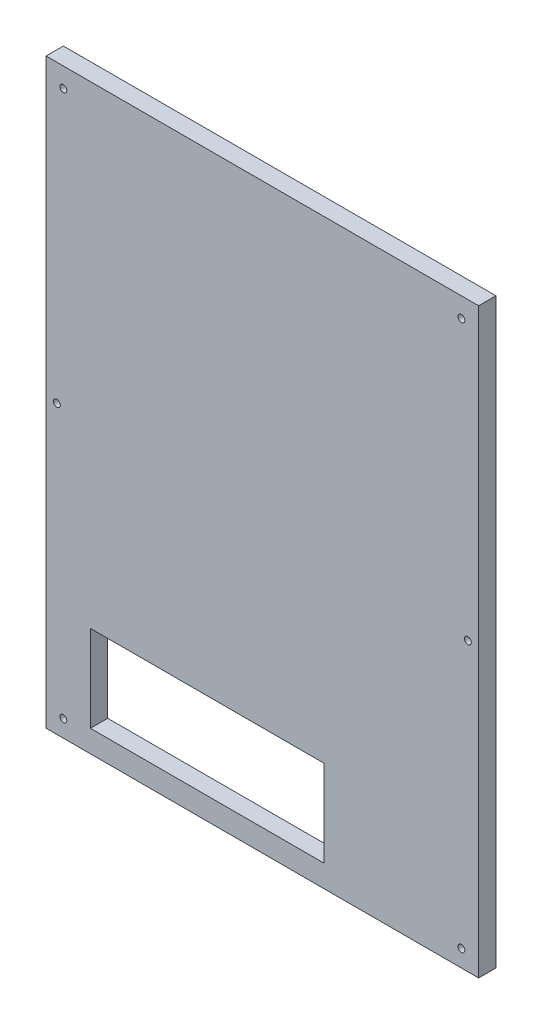
from build123d import *

# Parameters (mm, degrees)
CROQUIS1_W              = 250
CROQUIS1_H              = 336.42
SALIENTE_EXTRUIR1_DEPTH = 10
CORTAR_EXTRUIR1_REACH   = 12
CROQUIS2_R              = 2
CORTAR_EXTRUIR2_REACH   = 12
CROQUIS3_W              = 135
CROQUIS3_H              = 50


with BuildPart() as part:
    # Croquis1 → Saliente-Extruir1 (new body)
    with BuildSketch(Plane.XY):
        Rectangle(CROQUIS1_W, CROQUIS1_H)
    extrude(amount=SALIENTE_EXTRUIR1_DEPTH)

    # Croquis2 → Cortar-Extruir1 (cut, up to next)
    with BuildSketch(Plane(origin=(0, 0, 0), x_dir=(-1, 0, 0), z_dir=(0, 0, -1)), mode=Mode.PRIVATE) as cortar_extruir1_sk1:
        with Locations((115, 156.881750805)):
            Circle(CROQUIS2_R)
    cortar_extruir1_tool1 = extrude(cortar_extruir1_sk1.sketch, amount=-CORTAR_EXTRUIR1_REACH, mode=Mode.PRIVATE) & part.part
    add(cortar_extruir1_tool1.solids().sort_by_distance((-115, 156.881751, 0))[0], mode=Mode.SUBTRACT)
    # Croquis2 → Cortar-Extruir1 (cut, up to next)
    with BuildSketch(Plane(origin=(0, 0, 0), x_dir=(-1, 0, 0), z_dir=(0, 0, -1)), mode=Mode.PRIVATE) as cortar_extruir1_sk2:
        with Locations((-115, 156.881750805)):
            Circle(CROQUIS2_R)
    cortar_extruir1_tool2 = extrude(cortar_extruir1_sk2.sketch, amount=-CORTAR_EXTRUIR1_REACH, mode=Mode.PRIVATE) & part.part
    add(cortar_extruir1_tool2.solids().sort_by_distance((115, 156.881751, 0))[0], mode=Mode.SUBTRACT)
    # Croquis2 → Cortar-Extruir1 (cut, up to next)
    with BuildSketch(Plane(origin=(0, 0, 0), x_dir=(-1, 0, 0), z_dir=(0, 0, -1)), mode=Mode.PRIVATE) as cortar_extruir1_sk3:
        with Locations((-118.75, -2.472724195)):
            Circle(CROQUIS2_R)
    cortar_extruir1_tool3 = extrude(cortar_extruir1_sk3.sketch, amount=-CORTAR_EXTRUIR1_REACH, mode=Mode.PRIVATE) & part.part
    add(cortar_extruir1_tool3.solids().sort_by_distance((118.75, -2.472724, 0))[0], mode=Mode.SUBTRACT)
    # Croquis2 → Cortar-Extruir1 (cut, up to next)
    with BuildSketch(Plane(origin=(0, 0, 0), x_dir=(-1, 0, 0), z_dir=(0, 0, -1)), mode=Mode.PRIVATE) as cortar_extruir1_sk4:
        with Locations((118.75, -2.472724195)):
            Circle(CROQUIS2_R)
    cortar_extruir1_tool4 = extrude(cortar_extruir1_sk4.sketch, amount=-CORTAR_EXTRUIR1_REACH, mode=Mode.PRIVATE) & part.part
    add(cortar_extruir1_tool4.solids().sort_by_distance((-118.75, -2.472724, 0))[0], mode=Mode.SUBTRACT)
    # Croquis2 → Cortar-Extruir1 (cut, up to next)
    with BuildSketch(Plane(origin=(0, 0, 0), x_dir=(-1, 0, 0), z_dir=(0, 0, -1)), mode=Mode.PRIVATE) as cortar_extruir1_sk5:
        with Locations((-115, -158.388099131)):
            Circle(CROQUIS2_R)
    cortar_extruir1_tool5 = extrude(cortar_extruir1_sk5.sketch, amount=-CORTAR_EXTRUIR1_REACH, mode=Mode.PRIVATE) & part.part
    add(cortar_extruir1_tool5.solids().sort_by_distance((115, -158.388099, 0))[0], mode=Mode.SUBTRACT)
    # Croquis2 → Cortar-Extruir1 (cut, up to next)
    with BuildSketch(Plane(origin=(0, 0, 0), x_dir=(-1, 0, 0), z_dir=(0, 0, -1)), mode=Mode.PRIVATE) as cortar_extruir1_sk6:
        with Locations((115, -158.388099131)):
            Circle(CROQUIS2_R)
    cortar_extruir1_tool6 = extrude(cortar_extruir1_sk6.sketch, amount=-CORTAR_EXTRUIR1_REACH, mode=Mode.PRIVATE) & part.part
    add(cortar_extruir1_tool6.solids().sort_by_distance((-115, -158.388099, 0))[0], mode=Mode.SUBTRACT)

    # Croquis3 → Cortar-Extruir2 (cut, up to next)
    with BuildSketch(Plane(origin=(0, 0, 0), x_dir=(-1, 0, 0), z_dir=(0, 0, -1)), mode=Mode.PRIVATE) as cortar_extruir2_sk1:
        with Locations((31.860667122, -130.421960957)):
            Rectangle(CROQUIS3_W, CROQUIS3_H)
    cortar_extruir2_tool1 = extrude(cortar_extruir2_sk1.sketch, amount=-CORTAR_EXTRUIR2_REACH, mode=Mode.PRIVATE) & part.part
    add(cortar_extruir2_tool1.solids().sort_by_distance((-31.860667, -130.421961, 0))[0], mode=Mode.SUBTRACT)


solid = part.part
